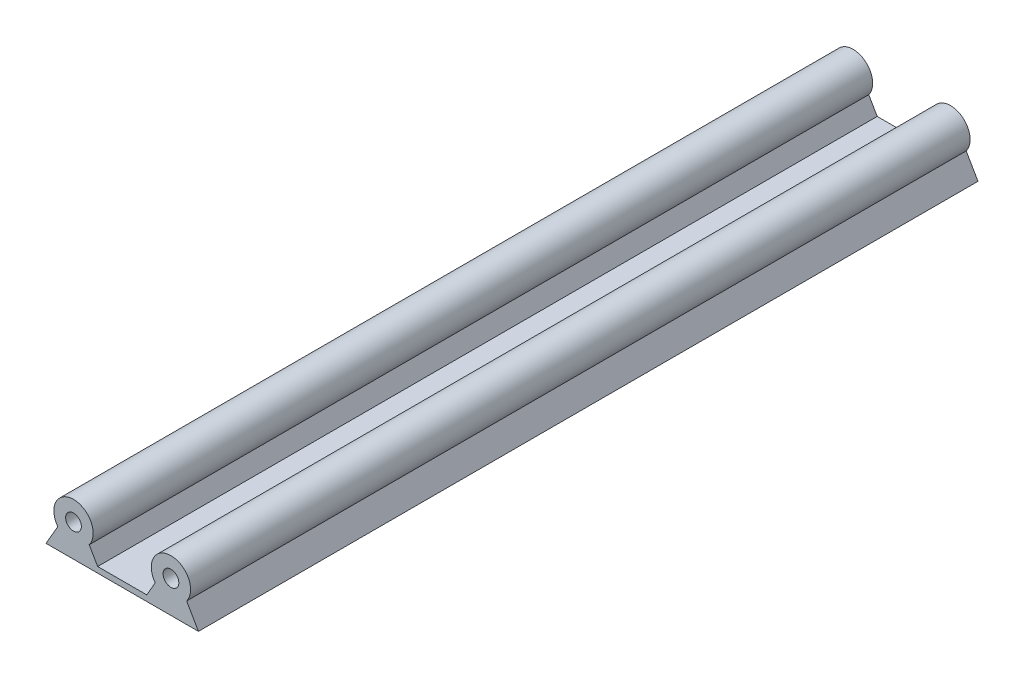
from build123d import *

# Parameters (mm, degrees)
SKETCH1_R           = 5
BOSS_EXTRUDE1_DEPTH = 220
BOSS_EXTRUDE4_DEPTH = 220
SKETCH5_R           = 1.37
CUT_EXTRUDE1_DEPTH  = 7
SKETCH6_R           = 1.37
CUT_EXTRUDE2_DEPTH  = 7
CUT_EXTRUDE4_DEPTH  = 10.8
CUT_EXTRUDE5_DEPTH  = 10.8
SKETCH11_R          = 2
CUT_EXTRUDE6_DEPTH  = 7
SKETCH12_R          = 1.5
CUT_EXTRUDE7_DEPTH  = 7
SKETCH4_R           = 3.2
CUT_EXTRUDE9_DEPTH  = 5


with BuildPart() as part:
    # Sketch1 → Boss-Extrude1 (new body)
    with BuildSketch(Plane.XY):
        Circle(SKETCH1_R)
        with BuildLine():
            Line((-4, -3), (-7, -8.196152423))
            Line((-7, -8.196152423), (7, -8.196152423))
            Line((7, -8.196152423), (4, -3))
            ThreePointArc((4, -3), (0, 5), (-4, -3))
        make_face()
        with BuildLine():
            Line((28.8, -3), (31.8, -8.196152423))
            Line((31.8, -8.196152423), (17.8, -8.196152423))
            Line((17.8, -8.196152423), (20.8, -3))
            ThreePointArc((20.8, -3), (24.8, 5), (28.8, -3))
        make_face()
    extrude(amount=BOSS_EXTRUDE1_DEPTH)

    # Sketch3 → Boss-Extrude4 (add)
    with BuildSketch(Plane.XY.offset(220)):
        Polygon((7, -8.196152423), (17.8, -8.196152423), (18.65, -8.196152423), (18.65, -6.723909236), (6.15, -6.723909236), (6.15, -8.196152423), align=None)
    extrude(amount=-BOSS_EXTRUDE4_DEPTH)

    # Sketch5 → Cut-Extrude1 (cut)
    with BuildSketch(Plane(origin=(0, 0, 0), x_dir=(-1, 0, 0), z_dir=(0, 0, -1))):
        Circle(SKETCH5_R)
        with Locations((-24.8, 0)):
            Circle(SKETCH5_R)
    extrude(amount=-CUT_EXTRUDE1_DEPTH, mode=Mode.SUBTRACT)

    # Sketch6 → Cut-Extrude2 (cut)
    with BuildSketch(Plane.XY.offset(220)):
        Circle(SKETCH6_R)
        with Locations((24.8, 0)):
            Circle(SKETCH6_R)
    extrude(amount=-CUT_EXTRUDE2_DEPTH, mode=Mode.SUBTRACT)

    # Sketch9 → Cut-Extrude4 (cut)
    with BuildSketch(Plane(origin=(0, 0, 0), x_dir=(-1, 0, 0), z_dir=(0, 0, -1))):
        with BuildLine():
            Line((-28.8, -3), (-31.8, -8.196152423))
            Line((-31.8, -8.196152423), (7, -8.196152423))
            Line((7, -8.196152423), (4, -3))
            ThreePointArc((4, -3), (0, 5), (-4, -3))
            Line((-4, -3), (-6.15, -6.723909236))
            Line((-6.15, -6.723909236), (-18.65, -6.723909236))
            Line((-18.65, -6.723909236), (-20.8, -3))
            ThreePointArc((-20.8, -3), (-24.8, 5), (-28.8, -3))
        make_face()
    extrude(amount=-CUT_EXTRUDE4_DEPTH, mode=Mode.SUBTRACT)

    # Sketch10 → Cut-Extrude5 (cut)
    with BuildSketch(Plane.XY.offset(220)):
        with BuildLine():
            Line((20.8, -3), (18.65, -6.723909236))
            Line((18.65, -6.723909236), (6.15, -6.723909236))
            Line((6.15, -6.723909236), (4, -3))
            ThreePointArc((4, -3), (0, 5), (-4, -3))
            Line((-4, -3), (-7, -8.196152423))
            Line((-7, -8.196152423), (31.8, -8.196152423))
            Line((31.8, -8.196152423), (28.8, -3))
            ThreePointArc((28.8, -3), (24.8, 5), (20.8, -3))
        make_face()
    extrude(amount=-CUT_EXTRUDE5_DEPTH, mode=Mode.SUBTRACT)

    # Sketch11 → Cut-Extrude6 (cut)
    with BuildSketch(Plane.XY.offset(209.2)):
        Circle(SKETCH11_R)
        with Locations((24.8, 0)):
            Circle(SKETCH11_R)
    extrude(amount=-CUT_EXTRUDE6_DEPTH, mode=Mode.SUBTRACT)

    # Sketch12 → Cut-Extrude7 (cut)
    with BuildSketch(Plane(origin=(0, 0, 10.8), x_dir=(-1, 0, 0), z_dir=(0, 0, -1))):
        Circle(SKETCH12_R)
        with Locations((-24.8, 0)):
            Circle(SKETCH12_R)
    extrude(amount=-CUT_EXTRUDE7_DEPTH, mode=Mode.SUBTRACT)

    # Sketch4 → Cut-Extrude9 (cut)
    with BuildSketch(Plane.XZ.offset(8.196152423)):
        with Locations((0, 23.2)):
            Circle(SKETCH4_R)
        with Locations((24.8, 23.2)):
            Circle(SKETCH4_R)
        with Locations((0, 198.2)):
            Circle(SKETCH4_R)
        with Locations((24.8, 198.2)):
            Circle(SKETCH4_R)
    extrude(amount=-CUT_EXTRUDE9_DEPTH, mode=Mode.SUBTRACT)


solid = part.part
